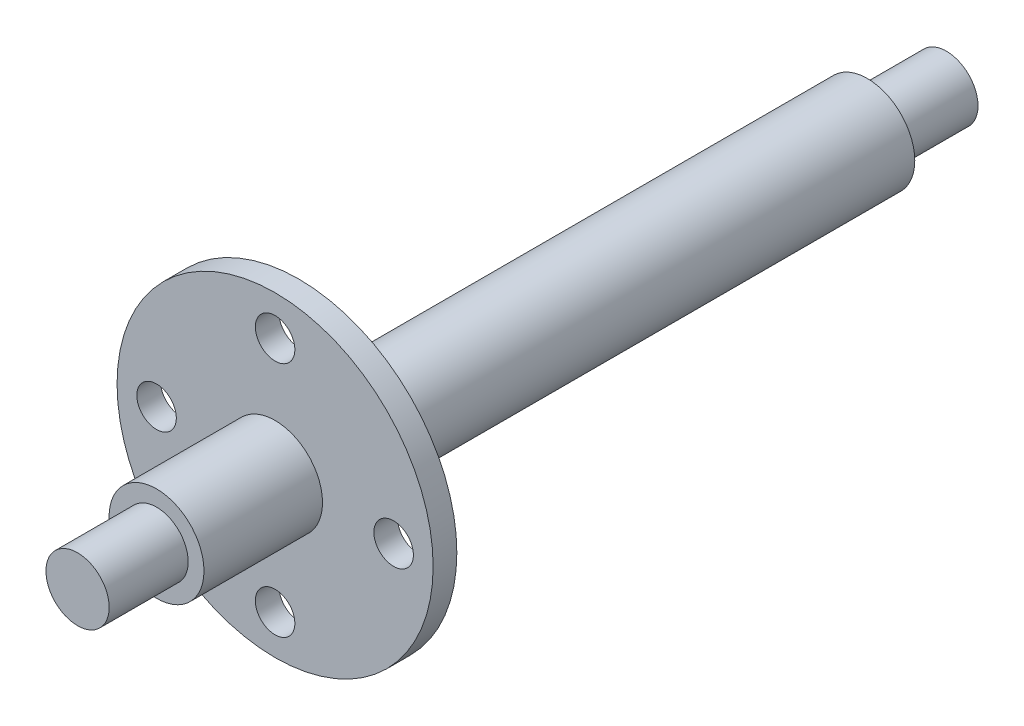
from build123d import *

# Parameters (mm, degrees)
SKETCH1_R           = 6
BOSS_EXTRUDE1_DEPTH = 109.95
SKETCH2_R           = 20
SKETCH2_R_2         = 2.5
BOSS_EXTRUDE2_DEPTH = 3
SKETCH3_R           = 6
SKETCH3_R_2         = 4
CUT_EXTRUDE1_DEPTH  = 10


with BuildPart() as part:
    # Sketch1 → Boss-Extrude1 (new body)
    with BuildSketch(Plane.XY):
        Circle(SKETCH1_R)
    extrude(amount=BOSS_EXTRUDE1_DEPTH)

    # Sketch2 → Boss-Extrude2 (add)
    with BuildSketch(Plane.XY.offset(81.95)):
        Circle(SKETCH2_R)
        with Locations((0, 15)):
            Circle(SKETCH2_R_2, mode=Mode.SUBTRACT)
        with Locations((15, 0)):
            Circle(SKETCH2_R_2, mode=Mode.SUBTRACT)
        with Locations((0, -15)):
            Circle(SKETCH2_R_2, mode=Mode.SUBTRACT)
        with Locations((-15, 0)):
            Circle(SKETCH2_R_2, mode=Mode.SUBTRACT)
    extrude(amount=BOSS_EXTRUDE2_DEPTH)

    # Sketch3 → Cut-Extrude1 (cut)
    with BuildSketch(Plane.XY.offset(109.95)):
        Circle(SKETCH3_R)
        Circle(SKETCH3_R_2, mode=Mode.SUBTRACT)
    cut_extrude1 = extrude(amount=-CUT_EXTRUDE1_DEPTH, mode=Mode.SUBTRACT)

    # Mirror1: Cut-Extrude1 across plane
    add(cut_extrude1.mirror(Plane.XY.offset(54.975)), mode=Mode.SUBTRACT)


solid = part.part
